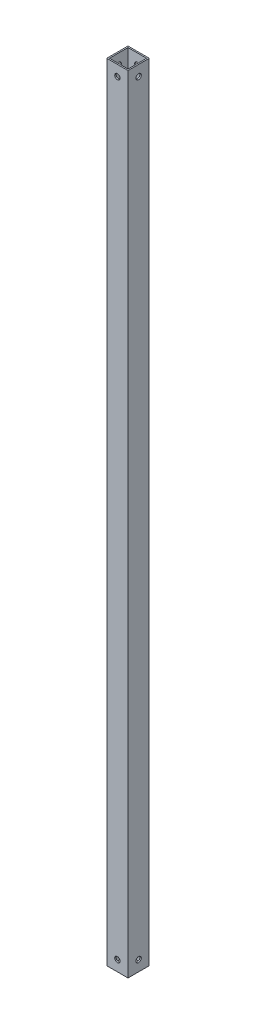
from build123d import *

# Parameters (mm, degrees)
SKETCH1_W           = 25.4
SKETCH1_H           = 25.4
SKETCH1_W_2         = 22.225
SKETCH1_H_2         = 22.225
BOSS_EXTRUDE1_DEPTH = 939.8
SKETCH2_R           = 3.175
CUT_EXTRUDE1_DEPTH  = 26.4
SKETCH3_R           = 3.175
CUT_EXTRUDE2_DEPTH  = 26.4


with BuildPart() as part:
    # Sketch1 → Boss-Extrude1 (new body)
    with BuildSketch(Plane(origin=(0, 0, 0), x_dir=(1, 0, 0), z_dir=(0, 1, 0))):
        Rectangle(SKETCH1_W, SKETCH1_H)
        Rectangle(SKETCH1_W_2, SKETCH1_H_2, mode=Mode.SUBTRACT)
    extrude(amount=BOSS_EXTRUDE1_DEPTH)

    # Sketch2 → Cut-Extrude1 (cut, through all)
    with BuildSketch(Plane(origin=(12.7, 0, 0), x_dir=(0, 0, -1), z_dir=(1, 0, 0))):
        with Locations((0, 12.7)):
            Circle(SKETCH2_R)
        with Locations((0, 927.1)):
            Circle(SKETCH2_R)
    extrude(amount=-CUT_EXTRUDE1_DEPTH, mode=Mode.SUBTRACT)

    # Sketch3 → Cut-Extrude2 (cut, through all)
    with BuildSketch(Plane.XY.offset(12.7)):
        with Locations((0, 12.7)):
            Circle(SKETCH3_R)
        with Locations((0, 927.1)):
            Circle(SKETCH3_R)
    extrude(amount=-CUT_EXTRUDE2_DEPTH, mode=Mode.SUBTRACT)


solid = part.part
